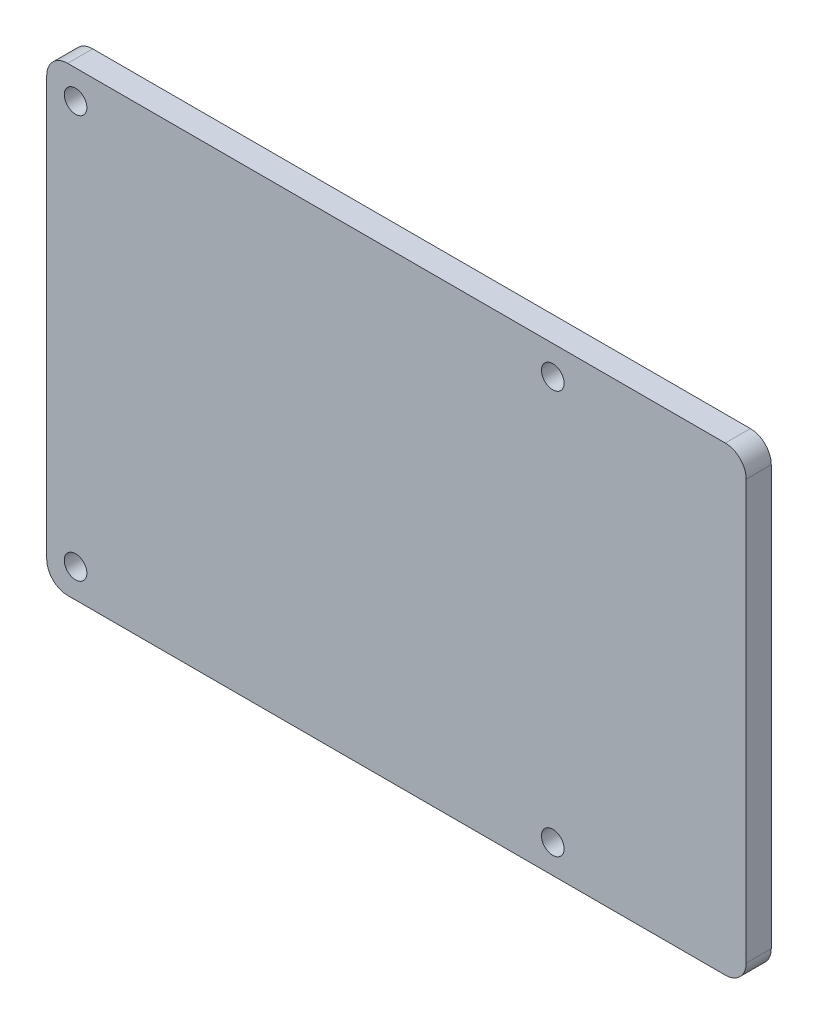
from build123d import *

# Parameters (mm, degrees)
SKETCH1_R           = 1.37499852
BOSS_EXTRUDE1_DEPTH = 3.048


with BuildPart() as part:
    # Sketch1 → Boss-Extrude1 (new body)
    with BuildSketch(Plane.XY):
        with BuildLine():
            Line((0.41036367, 15.02963974), (80.33963866, 15.02963974))
            ThreePointArc((80.33963866, 15.02963974), (82.135689884, 14.285690964), (82.87963866, 12.48963974))
            Line((82.87963866, 12.48963974), (82.87963866, -38.4396361))
            ThreePointArc((82.87963866, -38.4396361), (82.135689884, -40.235687324), (80.33963866, -40.9796361))
            Line((80.33963866, -40.9796361), (0.41036367, -40.9796361))
            ThreePointArc((0.41036367, -40.9796361), (-1.385687554, -40.235687324), (-2.12963633, -38.4396361))
            Line((-2.12963633, -38.4396361), (-2.12963633, 12.48963974))
            ThreePointArc((-2.12963633, 12.48963974), (-1.385687554, 14.285690964), (0.41036367, 15.02963974))
        make_face()
        with Locations((1.37500106, 11.52500108)):
            Circle(SKETCH1_R, mode=Mode.SUBTRACT)
        with Locations((59.3750019, 11.52500108)):
            Circle(SKETCH1_R, mode=Mode.SUBTRACT)
        with Locations((59.3750019, -37.47499998)):
            Circle(SKETCH1_R, mode=Mode.SUBTRACT)
        with Locations((1.37500106, -37.47499998)):
            Circle(SKETCH1_R, mode=Mode.SUBTRACT)
    extrude(amount=-BOSS_EXTRUDE1_DEPTH)


solid = part.part
